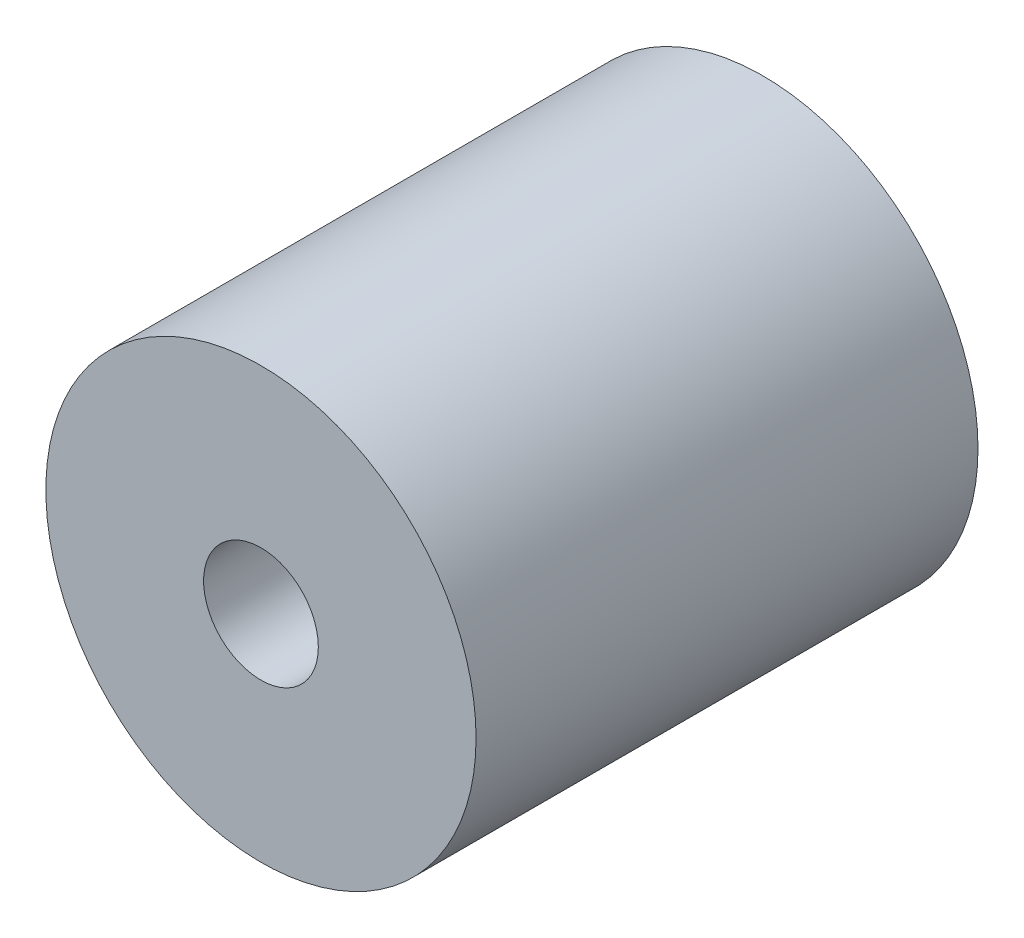
from build123d import *

# Parameters (mm, degrees)
SKETCH1_R          = 15
EXTRUDE1_DEPTH     = 35
SKETCH2_R          = 4
CUT_EXTRUDE1_DEPTH = 10
SKETCH3_R          = 6
CUT_EXTRUDE2_DEPTH = 10


with BuildPart() as part:
    # Sketch1 → Extrude1 (new body)
    with BuildSketch(Plane.XY):
        Circle(SKETCH1_R)
    extrude(amount=EXTRUDE1_DEPTH)

    # Sketch2 → Cut-Extrude1 (cut)
    with BuildSketch(Plane.XY.offset(35)):
        Circle(SKETCH2_R)
    extrude(amount=-CUT_EXTRUDE1_DEPTH, mode=Mode.SUBTRACT)

    # Sketch3 → Cut-Extrude2 (cut)
    with BuildSketch(Plane(origin=(0, 0, 0), x_dir=(-1, 0, 0), z_dir=(0, 0, -1))):
        Circle(SKETCH3_R)
    extrude(amount=-CUT_EXTRUDE2_DEPTH, mode=Mode.SUBTRACT)


solid = part.part
